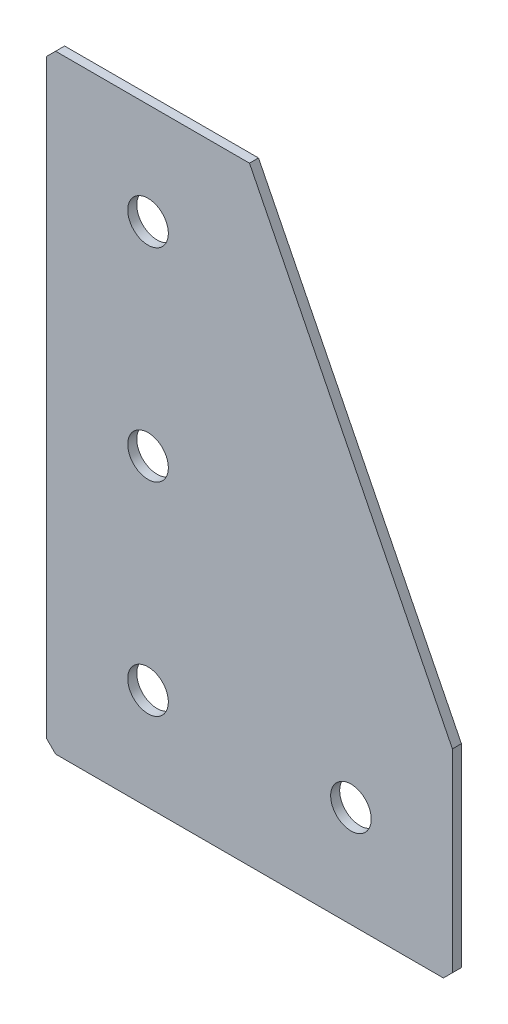
from build123d import *

# Parameters (mm, degrees)
EXTRUDE_1_DEPTH   = 2
HOLE_WIZARD_M81_D = 9
CHAMFER_1_SIZE    = 2


with BuildPart() as part:
    # Эскиз1 → Бобышка-Вытянуть1 (new body)
    with BuildSketch(Plane(origin=(0, 0, 0), x_dir=(1, 0, 0), z_dir=(0, 0, -1))):
        Polygon((0, 0), (0, 135), (90, 135), (90, 90), (45, 0), align=None)
    extrude(amount=EXTRUDE_1_DEPTH)

    # Отверстие с зазором M81 (through all)
    with Locations(Plane(origin=(0, 0, -2), x_dir=(1, 0, 0), z_dir=(0, 0, -1))):
        with Locations((67.5, 112.5), (22.5, 112.5), (22.5, 67.5), (22.5, 22.5)):
            Hole(HOLE_WIZARD_M81_D / 2)

    # Фаска1
    chamfer_1_edges = [part.edges().sort_by_distance(p)[0] for p in [
        (0, 0, -1),
        (0, -135, -1),
        (90, -135, -1),
    ]]
    chamfer(chamfer_1_edges, length=CHAMFER_1_SIZE)


solid = part.part
